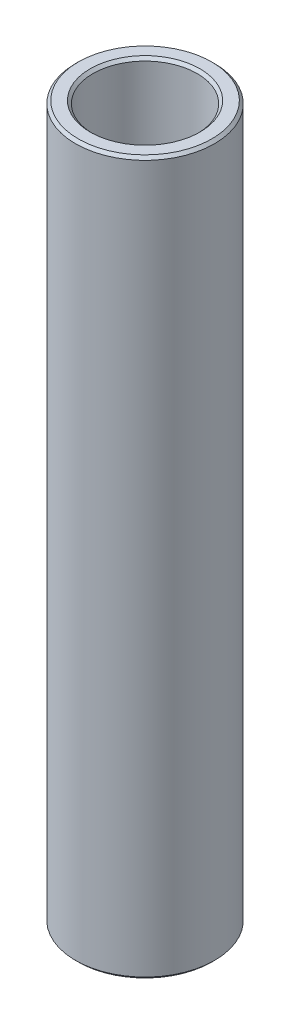
from build123d import *

# Parameters (mm, degrees)
SKETCH1_W     = 1.5875
SKETCH1_H     = 65.135434212
CHAMFER1_SIZE = 0.254


with BuildPart() as part:
    # Sketch1 → Revolve1 (revolve)
    with BuildSketch(Plane.XY):
        with Locations((5.55625, 103.211412071)):
            Rectangle(SKETCH1_W, SKETCH1_H)
    revolve(axis=Axis((0, 61.118694965, 0), (0, 1, 0)))

    # Chamfer1
    chamfer1_edges = [part.edges().sort_by_distance(p)[0] for p in [
        (-6.35, 70.643694965, 0),
        (-6.35, 135.779129177, 0),
        (-4.7625, 135.779129177, 0),
        (-4.7625, 70.643694965, 0),
    ]]
    chamfer(chamfer1_edges, length=CHAMFER1_SIZE)


solid = part.part
